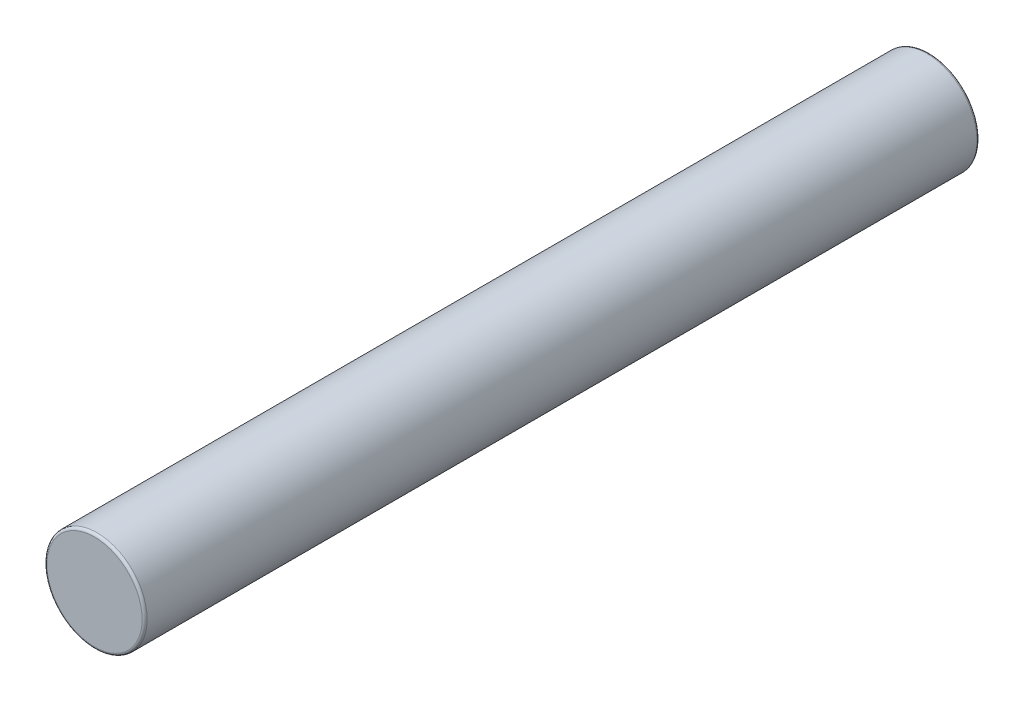
from build123d import *

# Parameters (mm, degrees)
SKETCH1_R           = 1.5
BOSS_EXTRUDE1_DEPTH = 25
FILLET1_R           = 0.075


with BuildPart() as part:
    # Sketch1 → Boss-Extrude1 (new body)
    with BuildSketch(Plane.XY):
        Circle(SKETCH1_R)
    extrude(amount=BOSS_EXTRUDE1_DEPTH)

    # Fillet1
    fillet1_edges = [part.edges().sort_by_distance(p)[0] for p in [
        (-1.5, 0, 0),
        (-1.5, 0, 25),
    ]]
    fillet(fillet1_edges, radius=FILLET1_R)


solid = part.part
